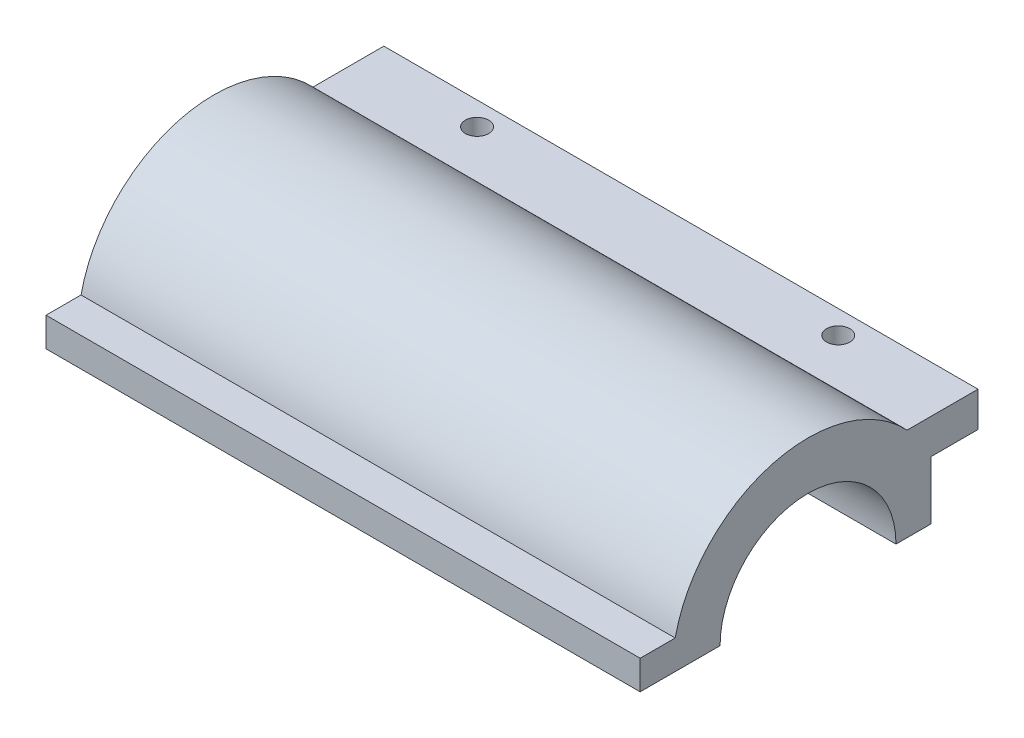
from build123d import *

# Parameters (mm, degrees)
BOSS_EXTRUDE1_DEPTH = 51
SKETCH2_R           = 1
CUT_EXTRUDE1_DEPTH  = 789


with BuildPart() as part:
    # Sketch1 → Boss-Extrude1 (new body)
    with BuildSketch(Plane(origin=(0, 0, 0), x_dir=(0, 0, -1), z_dir=(1, 0, 0))):
        with BuildLine():
            Line((12.15786554, -12.350689419), (15.15786554, -12.350689419))
            Line((15.15786554, -12.350689419), (15.15786554, -7.350689419))
            Line((15.15786554, -7.350689419), (19.19786554, -7.350689419))
            Line((19.19786554, -7.350689419), (19.19786554, -4.350689419))
            Line((19.19786554, -4.350689419), (13.110953215, -4.350689419))
            ThreePointArc((13.110953215, -4.350689419), (1.498781312, -1.097418994), (-6.796190756, -9.850689419))
            Line((-6.796190756, -9.850689419), (-9.80213446, -9.850689419))
            Line((-9.80213446, -9.850689419), (-9.80213446, -12.350689419))
            Line((-9.80213446, -12.350689419), (-2.94213446, -12.350689419))
            ThreePointArc((-2.94213446, -12.350689419), (4.60786554, -4.800689419), (12.15786554, -12.350689419))
        make_face()
    extrude(amount=BOSS_EXTRUDE1_DEPTH)

    # Sketch2 → Cut-Extrude1 (cut)
    with BuildSketch(Plane(origin=(0, -4.350689419, 0), x_dir=(1, 0, 0), z_dir=(0, 1, 0))):
        with Locations((10, 17.19786554)):
            Circle(SKETCH2_R)
        with Locations((41, 17.19786554)):
            Circle(SKETCH2_R)
    extrude(amount=-CUT_EXTRUDE1_DEPTH, mode=Mode.SUBTRACT)


solid = part.part
